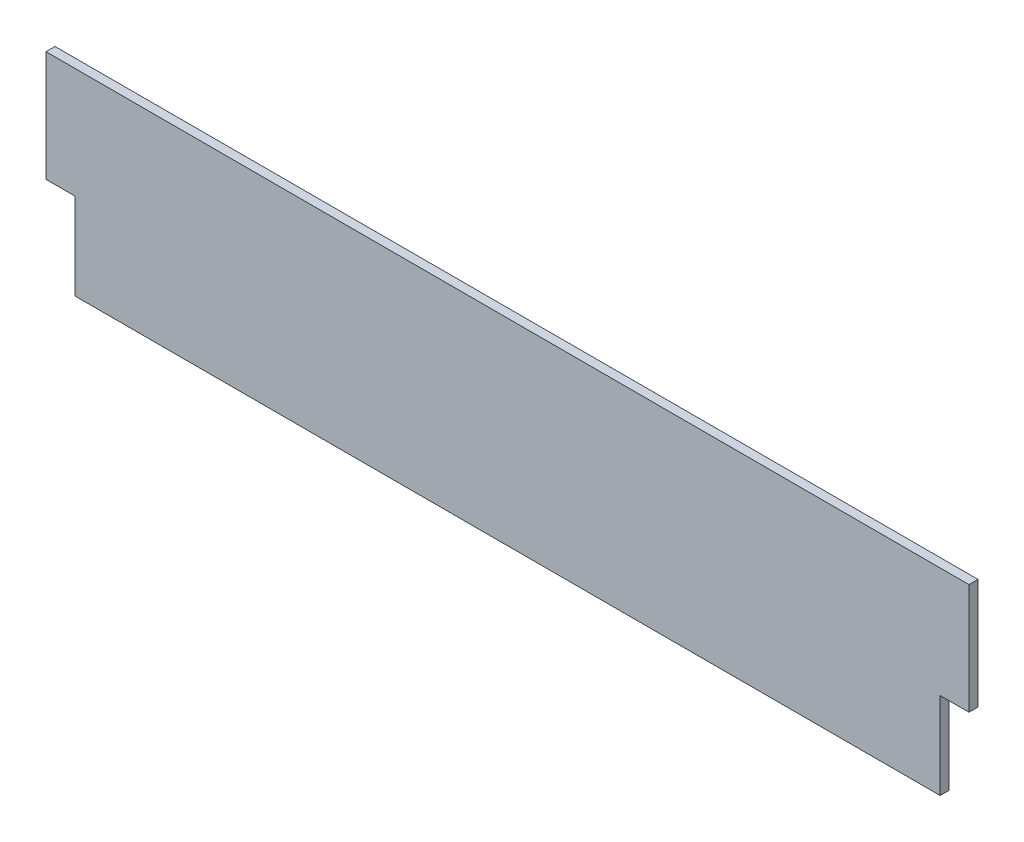
from build123d import *

# Parameters (mm, degrees)
BOSS_EXTRUDE1_DEPTH = 11.90625


with BuildPart() as part:
    # Sketch1 → Boss-Extrude1 (new body)
    with BuildSketch(Plane.XY):
        Polygon((50.853666255, -57.15), (1193.853666255, -57.15), (1193.853666255, 57.15), (1231.953666255, 57.15), (1231.953666255, 203.2), (12.753666255, 203.2), (12.753666255, 57.15), (50.853666255, 57.15), align=None)
    extrude(amount=BOSS_EXTRUDE1_DEPTH)


solid = part.part
